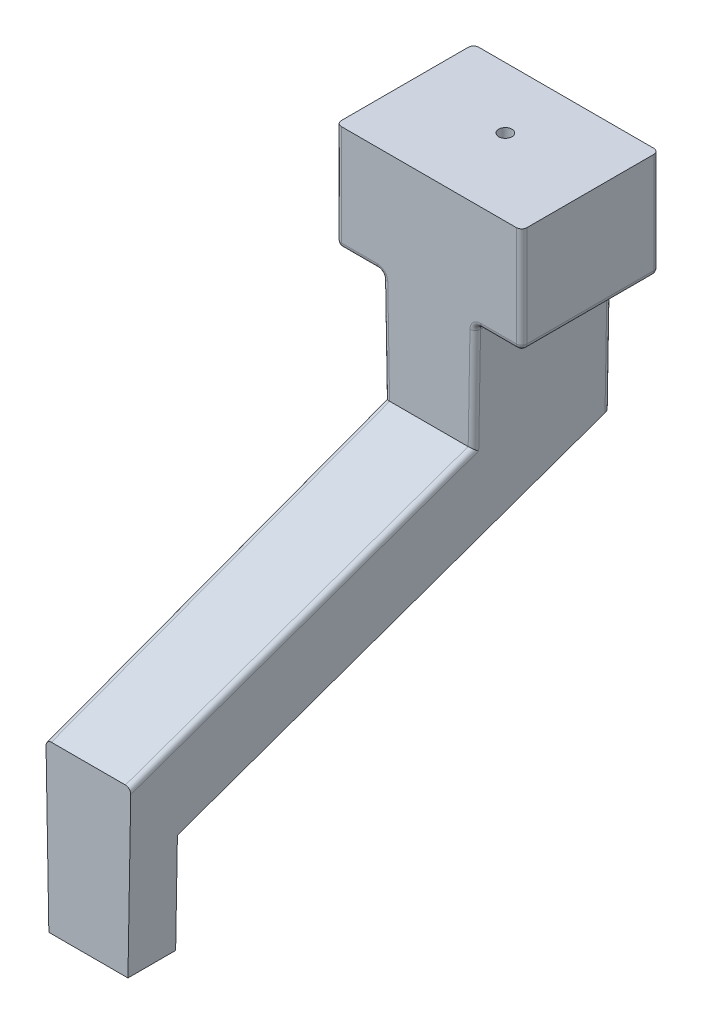
from build123d import *

# Parameters (mm, degrees)
BOSS_EXTRUDE1_DEPTH      = 1.5
SKETCH5_W                = 2.592520813
SKETCH5_H                = 2
BOSS_EXTRUDE2_DEPTH      = 1
BOSS_EXTRUDE2_DEPTH_BACK = 2.5
DRAFT1_ANGLE             = -1
FILLET1_R                = 0.1
SKETCH6_R                = 0.125
CUT_EXTRUDE1_DEPTH       = 2.5


with BuildPart() as part:
    # Sketch1 → Boss-Extrude1 (new body)
    with BuildSketch(Plane(origin=(0, 0, 0), x_dir=(0, 0, -1), z_dir=(1, 0, 0))):
        Polygon((-5.56205373, 1.669569419), (-5.56205373, -0.230430581), (-6.46205373, -0.230430581), (-6.46205373, 2.899223958), (-0.03891584, 5.23705496), (-0.03891584, 9.269569419), (2.553604973, 9.269569419), (2.553604973, 4.623427618), align=None)
    extrude(amount=BOSS_EXTRUDE1_DEPTH)

    # Sketch5 → Boss-Extrude2 (add, two sides)
    with BuildSketch(Plane.ZY) as boss_extrude2_sk:
        with Locations((-1.257344567, 8.269569419)):
            Rectangle(SKETCH5_W, SKETCH5_H)
    extrude(amount=BOSS_EXTRUDE2_DEPTH)
    extrude(boss_extrude2_sk.sketch, amount=-BOSS_EXTRUDE2_DEPTH_BACK)

    # Draft1
    draft1_faces = [part.faces().sort_by_distance(p)[0] for p in [
        (1.5, 4.069973974, 1.641347483),
        (0, 4.069973974, 1.641347483),
    ]]
    draft(draft1_faces, Plane.ZX, DRAFT1_ANGLE)

    # Fillet1
    fillet1_edges = [part.edges().sort_by_distance(p)[0] for p in [
        (-0.10915197, 6.253312189, 0.03891584),
        (-0.071009638, 4.068139459, 3.250484785),
        (1.603796518, 5.946498518, -2.553604973),
        (-0.126890806, 7.269569419, -1.257344566),
        (-0.563445403, 7.269569419, -2.553604973),
        (-0.563445403, 7.269569419, 0.03891584),
        (2.063445403, 7.269569419, -2.553604973),
        (2.5, 8.269569419, -2.553604973),
        (2.5, 8.269569419, 0.03891584),
        (2.063445403, 7.269569419, 0.03891584),
        (1.626890806, 7.269569419, -1.257344566),
        (2.5, 7.269569419, -1.257344566),
        (-1, 8.269569419, -2.553604973),
        (-1, 7.269569419, -1.257344566),
        (-1, 8.269569419, 0.03891584),
        (1.571009638, 4.068139459, 3.250484785),
        (1.60915197, 6.253312189, 0.03891584),
        (-0.103796518, 5.946498518, -2.553604973),
    ]]
    fillet(fillet1_edges, radius=FILLET1_R)

    # Sketch6 → Cut-Extrude1 (cut)
    with BuildSketch(Plane(origin=(0, 9.269569419, 0), x_dir=(1, 0, 0), z_dir=(0, 1, 0))):
        with Locations((0.75, 1.403604973)):
            Circle(SKETCH6_R)
    extrude(amount=-CUT_EXTRUDE1_DEPTH, mode=Mode.SUBTRACT)


solid = part.part
